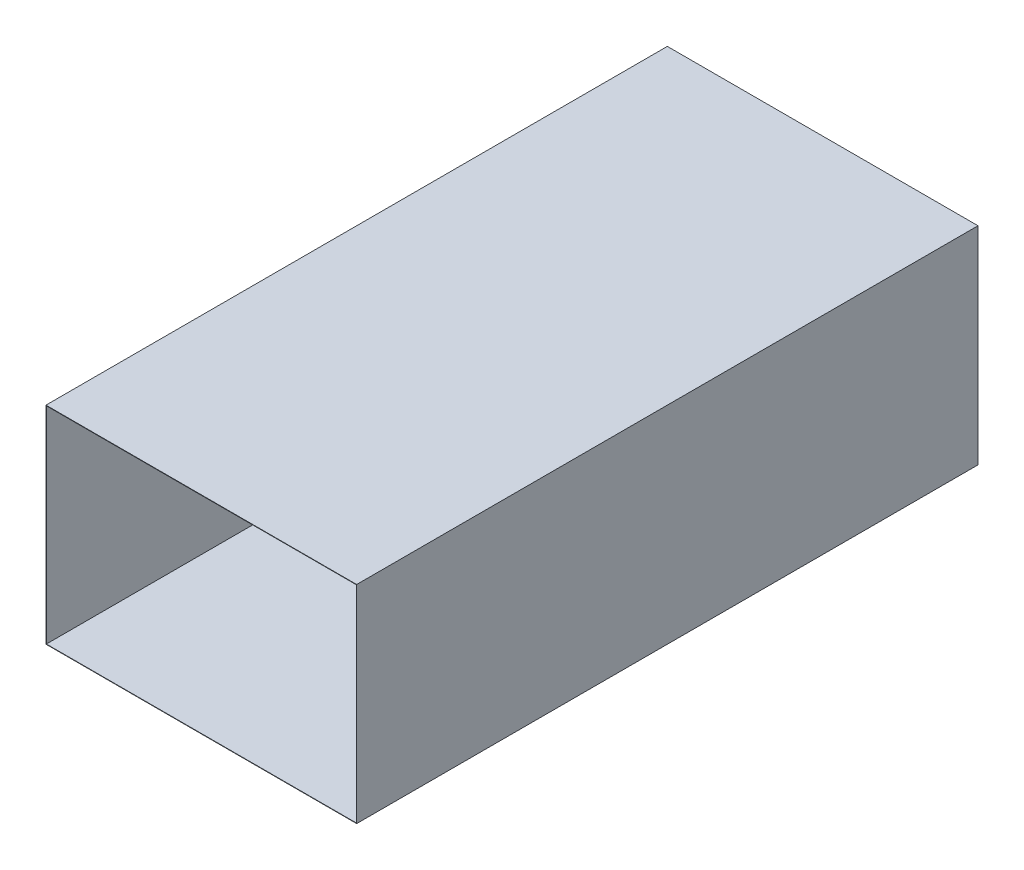
from build123d import *

# Parameters (mm, degrees)
DUCTSKETCH_W    = 1500
DUCTSKETCH_H    = 1000
DUCTSKETCH_W_2  = 1496
DUCTSKETCH_H_2  = 996
EXTRUSION_DEPTH = 3000


with BuildPart() as part:
    # DuctSketch → Extrusion (new body)
    with BuildSketch(Plane.XY):
        Rectangle(DUCTSKETCH_W, DUCTSKETCH_H)
        Rectangle(DUCTSKETCH_W_2, DUCTSKETCH_H_2, mode=Mode.SUBTRACT)
    extrude(amount=EXTRUSION_DEPTH)


solid = part.part
